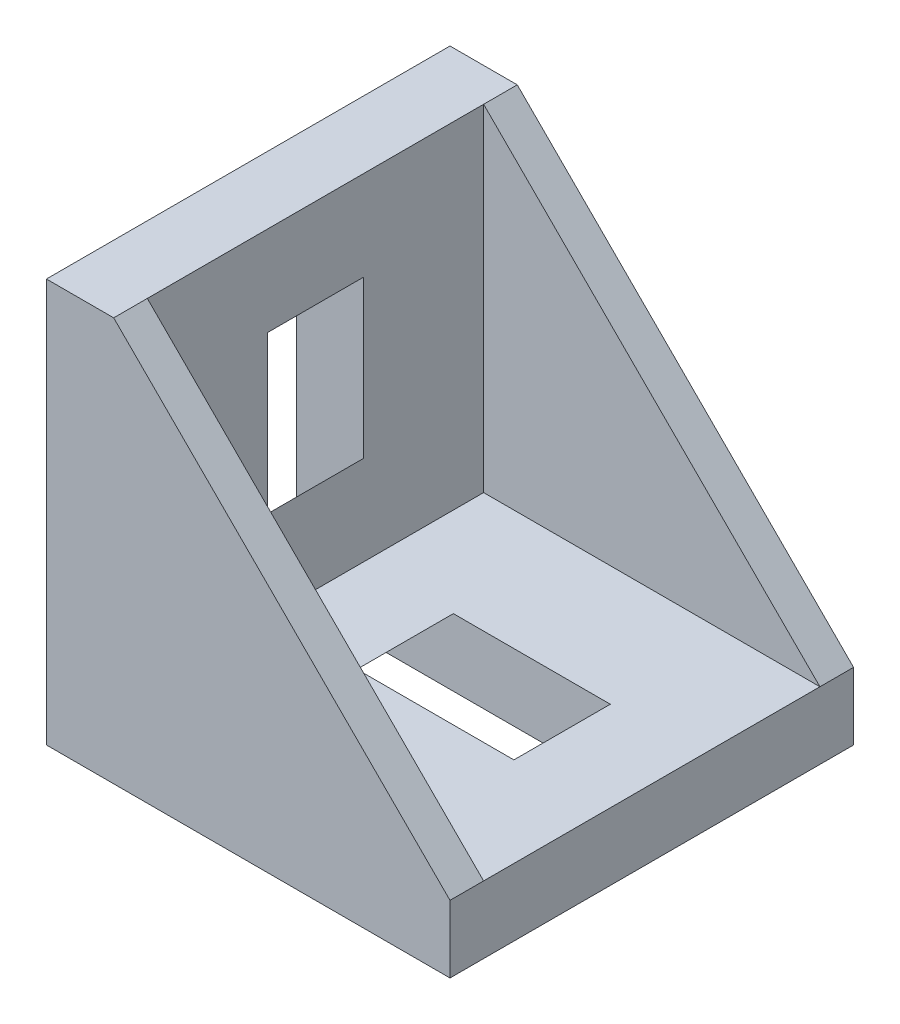
from build123d import *

# Parameters (mm, degrees)
BOSS_EXTRUDE1_DEPTH = 9
CUT_EXTRUDE1_DEPTH  = 7.5
CUT_EXTRUDE2_DEPTH  = 2.15
BOSS_EXTRUDE2_DEPTH = 2.5


with BuildPart() as part:
    # Sketch1 → Boss-Extrude1 (new body, symmetric)
    with BuildSketch(Plane.XY):
        Polygon((0, 0), (0, 18), (3, 18), (18, 3), (18, 0), align=None)
    extrude(amount=BOSS_EXTRUDE1_DEPTH, both=True)

    # Sketch2 → Cut-Extrude1 (cut, symmetric)
    with BuildSketch(Plane.XY):
        Polygon((3, 18), (3, 3), (18, 3), align=None)
    extrude(amount=CUT_EXTRUDE1_DEPTH, both=True, mode=Mode.SUBTRACT)

    # Sketch3 → Cut-Extrude2 (cut, symmetric)
    with BuildSketch(Plane.XY):
        Polygon((0, 14), (3, 14), (3, 7), (0, 4), align=None)
        Polygon((7, 3), (14, 3), (14, 0), (4, 0), align=None)
    extrude(amount=CUT_EXTRUDE2_DEPTH, both=True, mode=Mode.SUBTRACT)

    # Sketch4 → Boss-Extrude2 (add, symmetric)
    with BuildSketch(Plane.XY):
        Polygon((1.504575227, -1.8), (0.511249685, -0.790946088), (1.234750477, 0), (3.535533906, 0), align=None)
        Polygon((0, 3.535533906), (-1.8, 1.504575227), (-0.790946088, 0.511249685), (0, 1.234750477), align=None)
        Polygon((0, 17.3), (0, 14.999216572), (-0.790946088, 14.275715779), (-1.8, 15.269041321), align=None)
        Polygon((14.999216572, 0), (14.275715779, -0.790946088), (15.269041321, -1.8), (17.3, 0), align=None)
    extrude(amount=BOSS_EXTRUDE2_DEPTH, both=True)


solid = part.part
